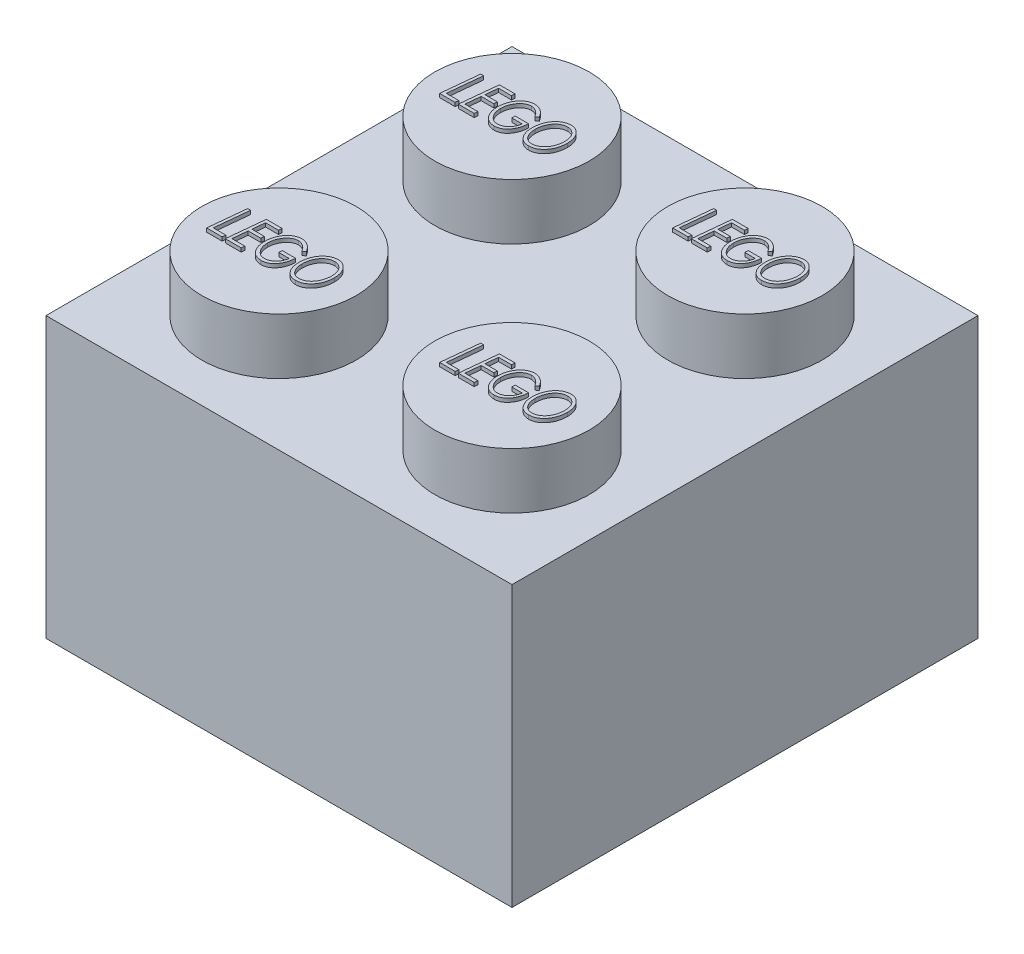
from build123d import *

# Parameters (mm, degrees)
SKETCH2_W            = 15.875
SKETCH2_H            = 15.875
BOSS_EXTRUDE3_DEPTH  = 9.525
SKETCH3_R            = 2.630752939
BOSS_EXTRUDE4_DEPTH  = 1.905
LPATTERN1_COUNT      = 2
LPATTERN1_PITCH      = 7.9375
LPATTERN1_COUNT_DIR2 = 2
LPATTERN1_PITCH_DIR2 = 7.9375
SHELL1_T             = -1.524
BOSS_EXTRUDE5_DEPTH  = 0.127
LPATTERN2_COUNT      = 2
LPATTERN2_PITCH      = 7.9375
LPATTERN2_COUNT_DIR2 = 2
LPATTERN2_PITCH_DIR2 = 7.9375
SKETCH5_R            = 3.175
SKETCH5_R_2          = 2.3876
BOSS_EXTRUDE6_DEPTH  = 8.001


with BuildPart() as part:
    # Sketch2 → Boss-Extrude3 (new body)
    with BuildSketch(Plane(origin=(0, 0, 0), x_dir=(1, 0, 0), z_dir=(0, 1, 0))):
        with Locations((-9.795613381, 0.785891089)):
            Rectangle(SKETCH2_W, SKETCH2_H)
    extrude(amount=BOSS_EXTRUDE3_DEPTH)

    # Sketch3 → Boss-Extrude4 (add)
    with BuildSketch(Plane(origin=(0, 9.525, 0), x_dir=(1, 0, 0), z_dir=(0, 1, 0))):
        with Locations((-13.764363381, 4.754641089)):
            Circle(SKETCH3_R)
    boss_extrude4 = extrude(amount=BOSS_EXTRUDE4_DEPTH)

    # LPattern1: Boss-Extrude4 2 × 2
    with Locations(*[(i * LPATTERN1_PITCH, 0, j * LPATTERN1_PITCH_DIR2) for i in range(LPATTERN1_COUNT) for j in range(LPATTERN1_COUNT_DIR2) if (i, j) != (0, 0)]):
        add(boss_extrude4)

    # Shell1
    shell1_openings = [part.faces().sort_by_distance(p)[0] for p in [
        (-9.795613381, 0, -0.785891089),
    ]]
    offset(amount=SHELL1_T, openings=shell1_openings, kind=Kind.INTERSECTION)

    # Sketch4 → Boss-Extrude5 (add)
    with BuildSketch(Plane(origin=(0, 11.43, 0), x_dir=(1, 0, 0), z_dir=(0, 1, 0))):
        Polygon((-15.421955913, 5.34660841), (-15.323500384, 5.34660841), (-15.441290849, 4.190582769), (-15.01414141, 4.190582769), (-15.02533532, 4.07660841), (-15.551449102, 4.07660841), align=None)
        Polygon((-14.248885, 5.34660841), (-14.262877387, 5.232634051), (-14.699694294, 5.232634051), (-14.742943493, 4.809300718), (-14.314013205, 4.809300718), (-14.326733557, 4.695326359), (-14.754646217, 4.695326359), (-14.806036442, 4.190582769), (-14.362859359, 4.190582769), (-14.374307676, 4.07660841), (-14.916449102, 4.07660841), (-14.786701506, 5.34660841), align=None)
        with BuildLine():
            Line((-13.157987564, 5.079226599), (-13.23685375, 5.004685333))
            add(Edge.make_bspline(
                [(-13.23685375, 5.004685333), (-13.243036349, 5.014919943), (-13.255215537, 5.03508124), (-13.274843903, 5.0639219), (-13.295404966, 5.090766309), (-13.316668722, 5.115943823), (-13.338681843, 5.139287343), (-13.361588027, 5.160749301), (-13.385450265, 5.180091456), (-13.409701872, 5.197942406), (-13.434658284, 5.213660022), (-13.459747782, 5.227481566), (-13.485177989, 5.238904833), (-13.510565197, 5.248734726), (-13.536282118, 5.256136896), (-13.562187777, 5.261089256), (-13.588089761, 5.264689825), (-13.605477312, 5.265029123), (-13.614139407, 5.265198154)],
                knots=[0, 0, 0, 0, 3.5867e-05, 7.0655e-05, 0.000104594, 0.000137266, 0.00016948, 0.0002008, 0.000231355, 0.000261581, 0.000291084, 0.000319773, 0.000347439, 0.000374655, 0.000401388, 0.000427582, 0.000453742, 0.000479711, 0.000479711, 0.000479711, 0.000479711], degree=3))
            add(Edge.make_bspline(
                [(-13.614139407, 5.265198154), (-13.623817018, 5.264942089), (-13.643246281, 5.264428001), (-13.672242613, 5.260605848), (-13.70083591, 5.253771652), (-13.729278127, 5.244988175), (-13.757272205, 5.233098144), (-13.785048709, 5.218900423), (-13.812373825, 5.20184576), (-13.839460855, 5.182752056), (-13.865426178, 5.16117013), (-13.890266569, 5.13792049), (-13.91359838, 5.112994152), (-13.935710508, 5.086452282), (-13.955872189, 5.057845897), (-13.975112242, 5.027830316), (-13.992587445, 4.995991744), (-14.008566347, 4.962671117), (-14.023015409, 4.928317995), (-14.035508966, 4.893155428), (-14.045942052, 4.857372561), (-14.054589121, 4.820944025), (-14.06149942, 4.783854091), (-14.066312673, 4.746142046), (-14.069143076, 4.707836031), (-14.069568079, 4.682101861), (-14.069782435, 4.669122433)],
                knots=[0, 0, 0, 0, 2.903e-05, 5.8283e-05, 8.7534e-05, 0.000117144, 0.000147477, 0.000178653, 0.000210636, 0.000244026, 0.000278, 0.000311837, 0.000346034, 0.000380367, 0.000415383, 0.000450953, 0.000487277, 0.000524259, 0.000561774, 0.000599029, 0.000636142, 0.000673537, 0.00071131, 0.000749271, 0.000787535, 0.000826472, 0.000826472, 0.000826472, 0.000826472], degree=3))
            add(Edge.make_bspline(
                [(-14.069782435, 4.669122433), (-14.069477418, 4.651721569), (-14.068877636, 4.617504752), (-14.063037479, 4.567164063), (-14.053971473, 4.518756671), (-14.041310983, 4.472223428), (-14.024646127, 4.42784351), (-14.004569657, 4.385349364), (-13.980409537, 4.345047805), (-13.953305264, 4.306998763), (-13.923509762, 4.272231716), (-13.891611692, 4.241833165), (-13.858241554, 4.215836332), (-13.822960448, 4.194859762), (-13.786317389, 4.177985595), (-13.747701019, 4.166780357), (-13.707804487, 4.159194772), (-13.680575585, 4.158413751), (-13.666801666, 4.158018667)],
                knots=[0, 0, 0, 0, 5.2184e-05, 0.000102614, 0.000151811, 0.000199829, 0.000247083, 0.000293853, 0.000340625, 0.000387856, 0.000433855, 0.000477763, 0.000519845, 0.000560465, 0.000600659, 0.0006405, 0.000680822, 0.0007221, 0.0007221, 0.0007221, 0.0007221], degree=3))
            add(Edge.make_bspline(
                [(-13.666801666, 4.158018667), (-13.650119891, 4.158598006), (-13.616764989, 4.159756384), (-13.567583001, 4.170959003), (-13.519199429, 4.187625511), (-13.472815147, 4.211693168), (-13.428975753, 4.24107788), (-13.3888146, 4.275137052), (-13.353443755, 4.314132031), (-13.322014522, 4.35741319), (-13.295472287, 4.406100752), (-13.27204085, 4.459501556), (-13.253441597, 4.518549092), (-13.244174766, 4.559989791), (-13.23939782, 4.581352)],
                knots=[0, 0, 0, 0, 4.9973e-05, 9.9921e-05, 0.000150611, 0.000203177, 0.000256167, 0.000308679, 0.000360721, 0.000413748, 0.000468753, 0.000526746, 0.000588456, 0.000654111, 0.000654111, 0.000654111, 0.000654111], degree=3))
            Line((-13.23939782, 4.581352), (-13.597602948, 4.581352))
            Line((-13.597602948, 4.581352), (-13.597602948, 4.695326359))
            Line((-13.597602948, 4.695326359), (-13.141705512, 4.695326359))
            add(Edge.make_bspline(
                [(-13.141705512, 4.695326359), (-13.143220249, 4.671630935), (-13.14618471, 4.625257073), (-13.156473523, 4.557663764), (-13.169882793, 4.493369383), (-13.188032162, 4.432650411), (-13.210191974, 4.37537214), (-13.236456597, 4.321477624), (-13.266757599, 4.270933421), (-13.300959259, 4.224225256), (-13.338414001, 4.182195788), (-13.37822362, 4.145176879), (-13.420442551, 4.113917018), (-13.464913787, 4.088167818), (-13.511934995, 4.06856876), (-13.561029266, 4.05415967), (-13.612484302, 4.045619356), (-13.647519936, 4.044574047), (-13.665275224, 4.044044308)],
                knots=[0, 0, 0, 0, 7.12e-05, 0.000139344, 0.00020491, 0.000268096, 0.00032923, 0.000388964, 0.000447735, 0.000505793, 0.000562373, 0.000616384, 0.000668589, 0.000719646, 0.000770156, 0.000821037, 0.000872858, 0.000926102, 0.000926102, 0.000926102, 0.000926102], degree=3))
            add(Edge.make_bspline(
                [(-13.665275224, 4.044044308), (-13.683458795, 4.044552296), (-13.719178417, 4.045550182), (-13.771372456, 4.054296421), (-13.821069071, 4.067841152), (-13.868065514, 4.087506656), (-13.912556407, 4.112374207), (-13.953984263, 4.143464588), (-13.993154071, 4.179412869), (-14.029026836, 4.220871562), (-14.061293356, 4.26652386), (-14.090007965, 4.315160597), (-14.113916063, 4.366865748), (-14.133555901, 4.421262957), (-14.148827293, 4.478548833), (-14.159713516, 4.538607223), (-14.166095756, 4.601566492), (-14.167008525, 4.644430286), (-14.167474743, 4.666323955)],
                knots=[0, 0, 0, 0, 5.4515e-05, 0.000107089, 0.00015832, 0.000208732, 0.000259537, 0.000310826, 0.000363759, 0.000418756, 0.000474947, 0.000531277, 0.000587959, 0.00064558, 0.000704576, 0.000765604, 0.000828511, 0.000894188, 0.000894188, 0.000894188, 0.000894188], degree=3))
            add(Edge.make_bspline(
                [(-14.167474743, 4.666323955), (-14.167185589, 4.682101713), (-14.16661133, 4.713436248), (-14.163381594, 4.759994442), (-14.157432775, 4.805749539), (-14.149274332, 4.850644315), (-14.139160769, 4.894945835), (-14.126422318, 4.938327925), (-14.111352878, 4.98094547), (-14.094155797, 5.022494256), (-14.074869439, 5.062577802), (-14.053847868, 5.100800933), (-14.03078607, 5.136684011), (-14.006484206, 5.170754132), (-13.979939226, 5.202226268), (-13.951836475, 5.231556391), (-13.922318071, 5.259016319), (-13.890824475, 5.283795413), (-13.858123028, 5.306042524), (-13.824881044, 5.325834039), (-13.790743443, 5.34211596), (-13.756112763, 5.355771227), (-13.720646944, 5.366079712), (-13.684726153, 5.373904452), (-13.648081628, 5.378221983), (-13.623478046, 5.378854133), (-13.611086522, 5.379172513)],
                knots=[0, 0, 0, 0, 4.7337e-05, 9.4011e-05, 0.000139924, 0.000185684, 0.000230857, 0.000276183, 0.000321242, 0.000366409, 0.000411014, 0.000454628, 0.000497184, 0.000538913, 0.000580086, 0.000620572, 0.000660721, 0.00070093, 0.000740658, 0.000779316, 0.000816866, 0.000854, 0.000890868, 0.000927543, 0.000964179, 0.001001354, 0.001001354, 0.001001354, 0.001001354], degree=3))
            add(Edge.make_bspline(
                [(-13.611086522, 5.379172513), (-13.599885481, 5.378887615), (-13.577690409, 5.378323085), (-13.544759644, 5.375041802), (-13.512580278, 5.369229816), (-13.481226926, 5.36060081), (-13.450309917, 5.350370482), (-13.420236456, 5.337162127), (-13.39072561, 5.322040578), (-13.362124517, 5.304229546), (-13.334002379, 5.284471776), (-13.306931369, 5.261858803), (-13.280001622, 5.237508559), (-13.254169985, 5.210414835), (-13.228831131, 5.181124192), (-13.20464202, 5.149192743), (-13.18043895, 5.115396141), (-13.16557029, 5.091442492), (-13.157987564, 5.079226599)],
                knots=[0, 0, 0, 0, 3.3606e-05, 6.6591e-05, 9.9176e-05, 0.000131574, 0.000164077, 0.000196781, 0.000230006, 0.000263473, 0.000297779, 0.000333024, 0.000369219, 0.000406644, 0.000445248, 0.000485345, 0.000526779, 0.000569901, 0.000569901, 0.000569901, 0.000569901], degree=3))
        make_face()
        with BuildLine():
            add(Edge.make_bspline(
                [(-12.369325705, 5.379172513), (-12.353010143, 5.378720522), (-12.32085994, 5.377829863), (-12.273715249, 5.369659659), (-12.22864765, 5.356507424), (-12.185856311, 5.337650018), (-12.145072326, 5.313842859), (-12.10647493, 5.284550539), (-12.070049375, 5.250024202), (-12.036169842, 5.210647693), (-12.00531375, 5.167406166), (-11.978235129, 5.120902684), (-11.955360597, 5.071642915), (-11.936357429, 5.019696609), (-11.921887955, 4.964835989), (-11.911994605, 4.907187182), (-11.905270318, 4.84685662), (-11.904608097, 4.805673345), (-11.904269615, 4.784623234)],
                knots=[0, 0, 0, 0, 4.8912e-05, 9.6383e-05, 0.000143072, 0.00018944, 0.000236302, 0.000284436, 0.000334467, 0.000386593, 0.000440034, 0.000493616, 0.000547793, 0.000602762, 0.000659349, 0.000717739, 0.000778115, 0.000841241, 0.000841241, 0.000841241, 0.000841241], degree=3))
            add(Edge.make_bspline(
                [(-11.904269615, 4.784623234), (-11.904724813, 4.758992871), (-11.905619371, 4.708623908), (-11.913649979, 4.634691374), (-11.926918957, 4.563951657), (-11.945042207, 4.49615546), (-11.969268607, 4.431731122), (-11.997812291, 4.369990143), (-12.032508136, 4.311855249), (-12.071636526, 4.257287391), (-12.11438555, 4.207292778), (-12.160684455, 4.163785264), (-12.209491268, 4.12681072), (-12.260952984, 4.096525947), (-12.315022525, 4.072933007), (-12.371712054, 4.05602052), (-12.43112154, 4.045889546), (-12.47164277, 4.044665448), (-12.49220431, 4.044044308)],
                knots=[0, 0, 0, 0, 7.6873e-05, 0.000151071, 0.000222773, 0.000292635, 0.000361299, 0.000429016, 0.000496426, 0.000564063, 0.000630262, 0.000693435, 0.00075429, 0.000813586, 0.000872147, 0.000930825, 0.000990675, 0.00105233, 0.00105233, 0.00105233, 0.00105233], degree=3))
            add(Edge.make_bspline(
                [(-12.49220431, 4.044044308), (-12.509616292, 4.04451494), (-12.543682005, 4.04543571), (-12.593480052, 4.053188575), (-12.640452828, 4.066244037), (-12.684989099, 4.084066344), (-12.726670432, 4.107489433), (-12.765818741, 4.135865921), (-12.802122503, 4.169487075), (-12.83534682, 4.207966726), (-12.865201071, 4.250535984), (-12.891189794, 4.296615807), (-12.91347966, 4.345682347), (-12.931507817, 4.398084844), (-12.945433182, 4.453595942), (-12.955221104, 4.512216375), (-12.961524863, 4.573921358), (-12.962237892, 4.616189815), (-12.962602948, 4.637830365)],
                knots=[0, 0, 0, 0, 5.2215e-05, 0.000102157, 0.000150733, 0.000198212, 0.000245705, 0.000293794, 0.000342944, 0.000393802, 0.000446031, 0.000498666, 0.000552293, 0.000607486, 0.000664684, 0.000723782, 0.000785651, 0.000850556, 0.000850556, 0.000850556, 0.000850556], degree=3))
            add(Edge.make_bspline(
                [(-12.962602948, 4.637830365), (-12.962348656, 4.654713021), (-12.961844621, 4.68817633), (-12.958119133, 4.737832996), (-12.952514622, 4.786550271), (-12.943616351, 4.83402181), (-12.933066316, 4.8806248), (-12.919782503, 4.926031082), (-12.904304725, 4.970508016), (-12.88616901, 5.013561667), (-12.866377445, 5.055186009), (-12.843997862, 5.094446642), (-12.820275911, 5.131646309), (-12.79433308, 5.166341896), (-12.767012283, 5.199072462), (-12.737321482, 5.229081319), (-12.705989763, 5.256911788), (-12.672917443, 5.282323432), (-12.638580562, 5.305193307), (-12.602929741, 5.324828759), (-12.566454338, 5.341794401), (-12.528918438, 5.355489869), (-12.490336002, 5.365956739), (-12.450894272, 5.373598515), (-12.410399159, 5.378302894), (-12.383076102, 5.378881385), (-12.369325705, 5.379172513)],
                knots=[0, 0, 0, 0, 5.0643e-05, 0.00010038, 0.000149323, 0.000197677, 0.000245196, 0.000292617, 0.000339526, 0.000386395, 0.000432706, 0.000477705, 0.000521881, 0.000564978, 0.000607585, 0.000649681, 0.000691492, 0.000733218, 0.000774708, 0.000815134, 0.000855202, 0.000895282, 0.000934843, 0.000975008, 0.001015717, 0.001056959, 0.001056959, 0.001056959, 0.001056959], degree=3))
        make_face()
        with BuildLine():
            add(Edge.make_bspline(
                [(-12.37059774, 5.265198154), (-12.382313596, 5.264974538), (-12.405384953, 5.264534185), (-12.43952799, 5.260405022), (-12.472806234, 5.254641281), (-12.50500305, 5.2453884), (-12.53641925, 5.23449868), (-12.566541003, 5.220073421), (-12.596086752, 5.204049224), (-12.624325369, 5.185085614), (-12.651275466, 5.163901314), (-12.677105719, 5.1407675), (-12.701242778, 5.115240955), (-12.723914887, 5.087622005), (-12.745319033, 5.058107871), (-12.765258418, 5.02643651), (-12.783453767, 4.992497975), (-12.800435903, 4.956872571), (-12.815618513, 4.919838387), (-12.828923446, 4.882001808), (-12.839728639, 4.843441788), (-12.848995625, 4.804516904), (-12.856130352, 4.764939705), (-12.861169544, 4.724771762), (-12.864339072, 4.683929196), (-12.8647191, 4.656492627), (-12.864910641, 4.642664099)],
                knots=[0, 0, 0, 0, 3.5131e-05, 6.9182e-05, 0.000103064, 0.000136333, 0.000169567, 0.000202688, 0.000236393, 0.000270332, 0.000304582, 0.000339169, 0.000374259, 0.000409863, 0.000446299, 0.000483568, 0.000522044, 0.000561759, 0.000601917, 0.000642065, 0.000682008, 0.000721995, 0.000762067, 0.000802584, 0.000843403, 0.000884884, 0.000884884, 0.000884884, 0.000884884], degree=3))
            add(Edge.make_bspline(
                [(-12.864910641, 4.642664099), (-12.864307988, 4.619656102), (-12.863131603, 4.574744224), (-12.854429419, 4.509171597), (-12.839695903, 4.447271889), (-12.822395219, 4.398577377), (-12.806018379, 4.361918699), (-12.792619836, 4.336186177), (-12.777779937, 4.312362342), (-12.762246178, 4.289966829), (-12.745390246, 4.269317365), (-12.727389498, 4.250238819), (-12.708171153, 4.232904881), (-12.688073445, 4.216982903), (-12.666766853, 4.20305699), (-12.644505145, 4.191085763), (-12.621414016, 4.180768501), (-12.597334266, 4.172401088), (-12.572284701, 4.166087649), (-12.546442494, 4.161495703), (-12.519659259, 4.158635539), (-12.50145487, 4.158226513), (-12.49220431, 4.158018667)],
                knots=[0, 0, 0, 0, 6.9012e-05, 0.000134712, 0.000198022, 0.000259579, 0.000289414, 0.000318432, 0.000346532, 0.000373564, 0.000400145, 0.00042642, 0.000452175, 0.000477724, 0.000503267, 0.000528424, 0.00055348, 0.000579065, 0.000604796, 0.000630896, 0.000657755, 0.000685504, 0.000685504, 0.000685504, 0.000685504], degree=3))
            add(Edge.make_bspline(
                [(-12.49220431, 4.158018667), (-12.481164543, 4.158226379), (-12.45926255, 4.158638462), (-12.426815915, 4.163069526), (-12.394912776, 4.169171543), (-12.363753517, 4.178557501), (-12.333054523, 4.1901992), (-12.30315314, 4.204836709), (-12.27362727, 4.221656145), (-12.245054493, 4.241259996), (-12.217396148, 4.263059149), (-12.191102552, 4.2869402), (-12.166751424, 4.31313992), (-12.143343282, 4.340857537), (-12.121926482, 4.370957713), (-12.101553921, 4.402800133), (-12.083509498, 4.437043875), (-12.066362584, 4.472756352), (-12.051268705, 4.510002211), (-12.037904005, 4.548157353), (-12.027111895, 4.587233797), (-12.017881689, 4.626845971), (-12.010718503, 4.667266057), (-12.005706916, 4.708370092), (-12.002526277, 4.750312827), (-12.002151397, 4.778511748), (-12.001961923, 4.79276426)],
                knots=[0, 0, 0, 0, 3.3097e-05, 6.5662e-05, 9.8093e-05, 0.000130454, 0.000163149, 0.000196488, 0.000230221, 0.000265008, 0.000300331, 0.000335806, 0.000371442, 0.000407566, 0.000444563, 0.000482183, 0.000520883, 0.000560598, 0.000600991, 0.00064138, 0.000681813, 0.000722543, 0.000763366, 0.000804893, 0.000846727, 0.000889479, 0.000889479, 0.000889479, 0.000889479], degree=3))
            add(Edge.make_bspline(
                [(-12.001961923, 4.79276426), (-12.002383429, 4.811264), (-12.003207157, 4.847417056), (-12.008729979, 4.900202516), (-12.018384404, 4.949996074), (-12.031884335, 4.996843587), (-12.049147304, 5.040781654), (-12.070413266, 5.081809748), (-12.095511146, 5.119934561), (-12.115257706, 5.142857206), (-12.125094935, 5.15427668)],
                knots=[0, 0, 0, 0, 5.5498e-05, 0.000108457, 0.000158999, 0.000207469, 0.000254523, 0.000300379, 0.00034589, 0.00039107, 0.00039107, 0.00039107, 0.00039107], degree=3))
            add(Edge.make_bspline(
                [(-12.125094935, 5.15427668), (-12.133669324, 5.163096064), (-12.150521626, 5.180429887), (-12.178137379, 5.203115094), (-12.206989058, 5.222389045), (-12.237249627, 5.237947562), (-12.268734009, 5.250365639), (-12.301624315, 5.258916547), (-12.335745739, 5.264150728), (-12.358876291, 5.264845883), (-12.37059774, 5.265198154)],
                knots=[0, 0, 0, 0, 3.6878e-05, 7.2482e-05, 0.000106986, 0.00014078, 0.00017437, 0.000208309, 0.000242526, 0.000277679, 0.000277679, 0.000277679, 0.000277679], degree=3))
        make_face(mode=Mode.SUBTRACT)
    boss_extrude5 = extrude(amount=BOSS_EXTRUDE5_DEPTH)

    # LPattern2: Boss-Extrude5 2 × 2
    with Locations(*[(i * LPATTERN2_PITCH, 0, j * LPATTERN2_PITCH_DIR2) for i in range(LPATTERN2_COUNT) for j in range(LPATTERN2_COUNT_DIR2) if (i, j) != (0, 0)]):
        add(boss_extrude5)

    # Sketch5 → Boss-Extrude6 (add)
    with BuildSketch(Plane.XZ):
        with Locations((-9.795613381, -0.785891089)):
            Circle(SKETCH5_R)
        with Locations((-9.795613381, -0.785891089)):
            Circle(SKETCH5_R_2, mode=Mode.SUBTRACT)
    extrude(amount=-BOSS_EXTRUDE6_DEPTH)


solid = part.part
